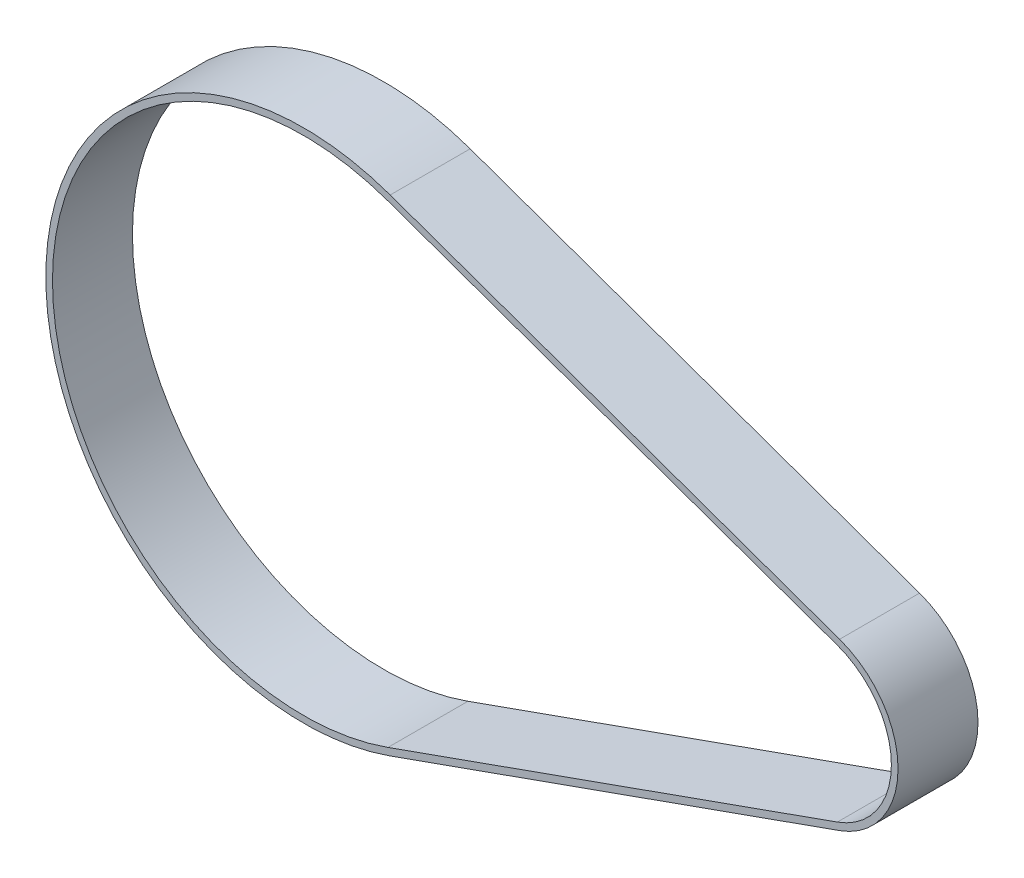
from build123d import *

# Parameters (mm, degrees)
SALIENTE_EXTRUIR1_DEPTH = 6


with BuildPart() as part:
    # Croquis1 → Saliente-Extruir1 (new body)
    with BuildSketch(Plane.XY):
        with BuildLine():
            Line((40.214473684, -6.217403502), (6.492434211, -18.22829663))
            ThreePointArc((6.492434211, -18.22829663), (-19.35, 0), (6.492434211, 18.22829663))
            Line((6.492434211, 18.22829663), (40.214473684, 6.217403502))
            ThreePointArc((40.214473684, 6.217403502), (44.6, 0), (40.214473684, -6.217403502))
        make_face()
        with BuildLine():
            Line((6.324671053, 17.757281213), (40.046710526, 5.746388085))
            ThreePointArc((40.046710526, 5.746388085), (44.1, 0), (40.046710526, -5.746388085))
            Line((40.046710526, -5.746388085), (6.324671053, -17.757281213))
            ThreePointArc((6.324671053, -17.757281213), (-18.85, 0), (6.324671053, 17.757281213))
        make_face(mode=Mode.SUBTRACT)
    extrude(amount=SALIENTE_EXTRUIR1_DEPTH)


solid = part.part
